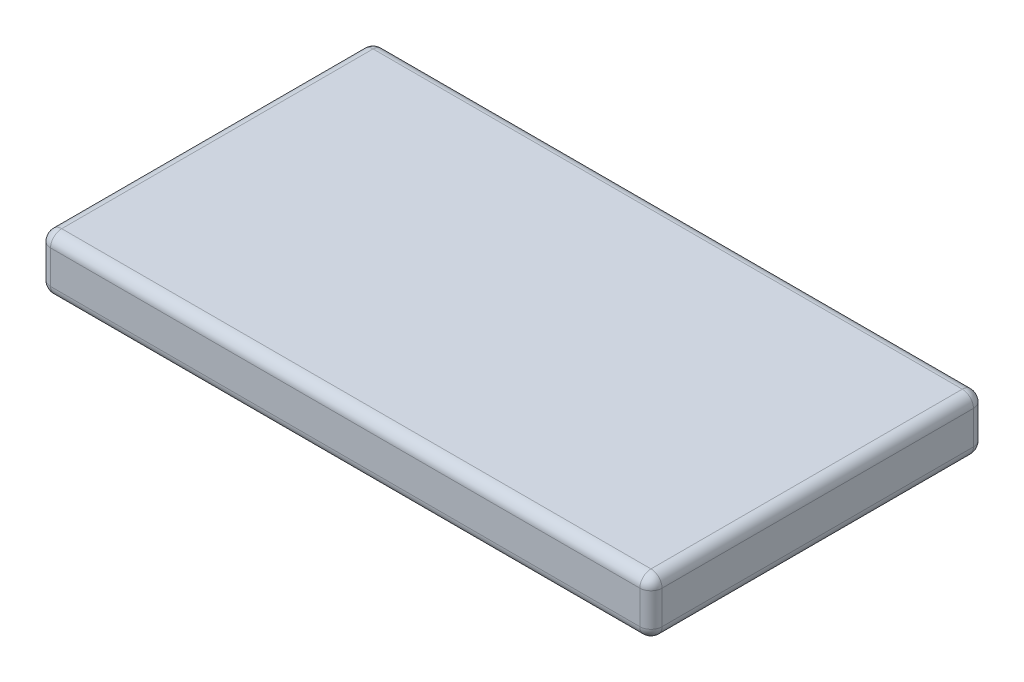
from build123d import *

# Parameters (mm, degrees)
SKETCH1_W   = 55
SKETCH1_H   = 30
SHAPE_DEPTH = 5
FILLETS_R   = 1


with BuildPart() as part:
    # Sketch1 → Shape (new body)
    with BuildSketch(Plane(origin=(0, 0, 0), x_dir=(1, 0, 0), z_dir=(0, 1, 0))):
        Rectangle(SKETCH1_W, SKETCH1_H)
    extrude(amount=SHAPE_DEPTH)

    # Fillets
    fillets_edges = [part.edges().sort_by_distance(p)[0] for p in [
        (-27.5, 5, 0),
        (0, 5, 15),
        (27.5, 5, 0),
        (0, 0, 15),
        (-27.5, 0, 0),
        (0, 0, -15),
        (27.5, 0, 0),
        (0, 5, -15),
        (27.5, 2.5, 15),
        (-27.5, 2.5, 15),
        (-27.5, 2.5, -15),
        (27.5, 2.5, -15),
    ]]
    fillet(fillets_edges, radius=FILLETS_R)


solid = part.part
